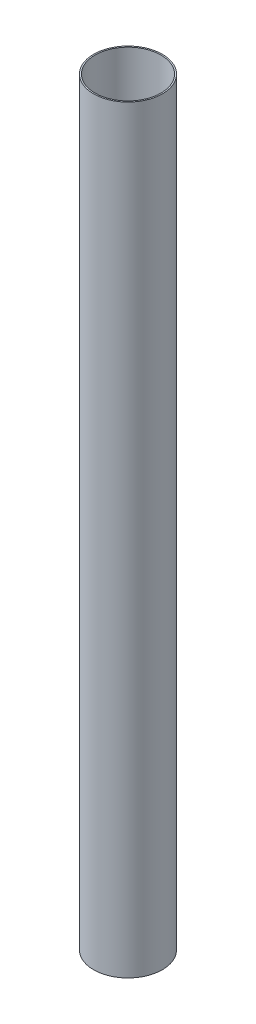
from build123d import *

# Parameters (mm, degrees)
SKETCH1_R           = 79.375
SKETCH1_R_2         = 76.2
BOSS_EXTRUDE1_DEPTH = 1752.6


with BuildPart() as part:
    # Sketch1 → Boss-Extrude1 (new body)
    with BuildSketch(Plane(origin=(0, 0, 0), x_dir=(1, 0, 0), z_dir=(0, 1, 0))):
        Circle(SKETCH1_R)
        Circle(SKETCH1_R_2, mode=Mode.SUBTRACT)
    extrude(amount=BOSS_EXTRUDE1_DEPTH)


solid = part.part
